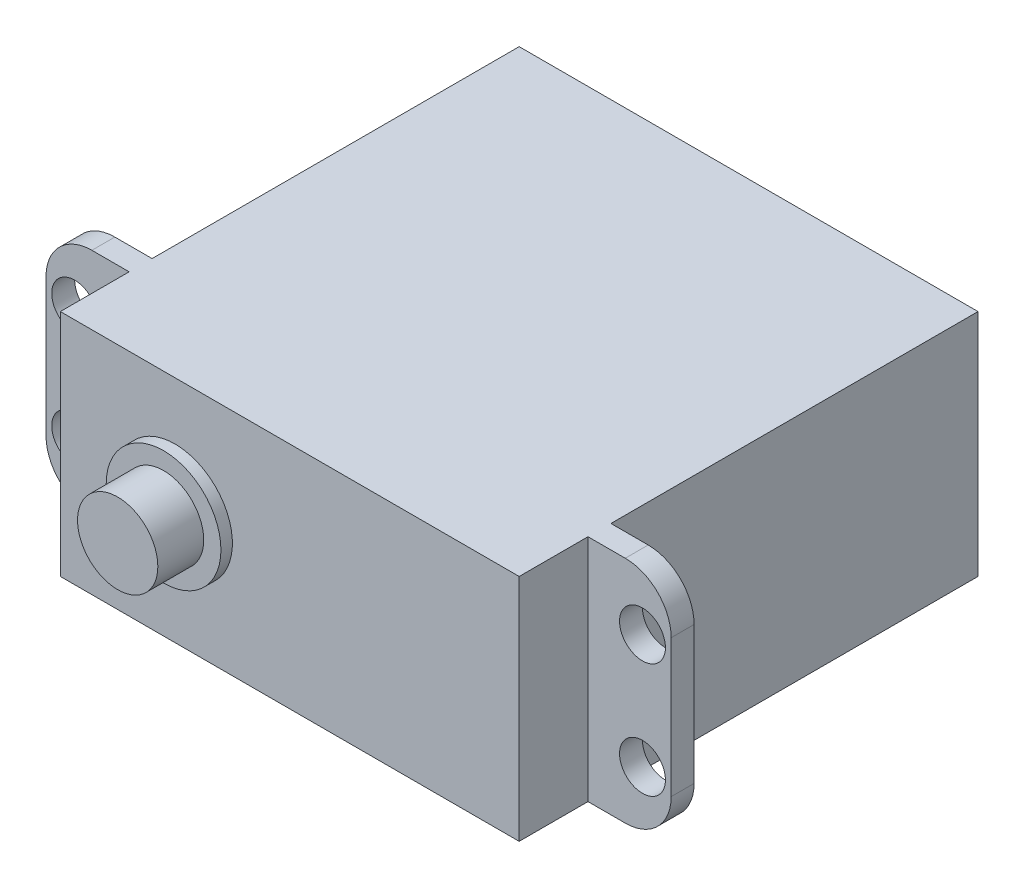
from build123d import *

# Parameters (mm, degrees)
SKETCH1_W           = 40
SKETCH1_H           = 20
BOSS_EXTRUDE2_DEPTH = 40
SKETCH2_W           = 2
SKETCH2_H           = 20
BOSS_EXTRUDE3_DEPTH = 7.25
SKETCH3_R           = 2
CUT_EXTRUDE1_DEPTH  = 2
FILLET3_R           = 4
SKETCH4_W           = 2
SKETCH4_H           = 20
BOSS_EXTRUDE4_DEPTH = 7.25
SKETCH5_R           = 2
CUT_EXTRUDE2_DEPTH  = 2
FILLET4_R           = 4
SKETCH6_R           = 5
BOSS_EXTRUDE5_DEPTH = 1
SKETCH7_R           = 3.5
BOSS_EXTRUDE7_DEPTH = 4
SKETCH9_R           = 5
BOSS_EXTRUDE8_DEPTH = 1
SKETCH10_R          = 3.5
BOSS_EXTRUDE9_DEPTH = 4


with BuildPart() as part:
    # Sketch1 → Boss-Extrude2 (new body)
    with BuildSketch(Plane.XY):
        Rectangle(SKETCH1_W, SKETCH1_H)
    extrude(amount=BOSS_EXTRUDE2_DEPTH)

    # Sketch2 → Boss-Extrude3 (add)
    with BuildSketch(Plane(origin=(20, 0, 0), x_dir=(0, 0, -1), z_dir=(1, 0, 0))):
        with Locations((-33, 0)):
            Rectangle(SKETCH2_W, SKETCH2_H)
    extrude(amount=BOSS_EXTRUDE3_DEPTH)

    # Sketch3 → Cut-Extrude1 (cut)
    with BuildSketch(Plane.XY.offset(34)):
        with Locations((24.75, -4.99913934)):
            Circle(SKETCH3_R)
        with Locations((24.75, 4.999429987)):
            Circle(SKETCH3_R)
    extrude(amount=-CUT_EXTRUDE1_DEPTH, mode=Mode.SUBTRACT)

    # Fillet3
    fillet3_edges = [part.edges().sort_by_distance(p)[0] for p in [
        (27.25, -10, 33),
        (27.25, 10, 33),
    ]]
    fillet(fillet3_edges, radius=FILLET3_R)

    # Sketch4 → Boss-Extrude4 (add)
    with BuildSketch(Plane.ZY.offset(20)):
        with Locations((33, 0)):
            Rectangle(SKETCH4_W, SKETCH4_H)
    extrude(amount=BOSS_EXTRUDE4_DEPTH)

    # Sketch5 → Cut-Extrude2 (cut)
    with BuildSketch(Plane.XY.offset(34)):
        with Locations((-24.75, 5)):
            Circle(SKETCH5_R)
        with Locations((-24.75, -5)):
            Circle(SKETCH5_R)
    extrude(amount=-CUT_EXTRUDE2_DEPTH, mode=Mode.SUBTRACT)

    # Fillet4
    fillet4_edges = [part.edges().sort_by_distance(p)[0] for p in [
        (-27.25, -10, 33),
        (-27.25, 10, 33),
    ]]
    fillet(fillet4_edges, radius=FILLET4_R)

    # Sketch6 → Boss-Extrude5 (add)
    with BuildSketch(Plane.XY.offset(40)):
        with Locations((-10, 0)):
            Circle(SKETCH6_R)
    extrude(amount=BOSS_EXTRUDE5_DEPTH)

    # Sketch7 → Boss-Extrude7 (add)
    with BuildSketch(Plane.XY.offset(41)):
        with Locations((-10, 0)):
            Circle(SKETCH7_R)
    extrude(amount=BOSS_EXTRUDE7_DEPTH)

    # Sketch9 → Boss-Extrude8 (add)
    with BuildSketch(Plane(origin=(0, 0, 0), x_dir=(-1, 0, 0), z_dir=(0, 0, -1))):
        with Locations((10, 0)):
            Circle(SKETCH9_R)
    extrude(amount=BOSS_EXTRUDE8_DEPTH)

    # Sketch10 → Boss-Extrude9 (add)
    with BuildSketch(Plane(origin=(0, 0, -1), x_dir=(-1, 0, 0), z_dir=(0, 0, -1))):
        with Locations((10, 0)):
            Circle(SKETCH10_R)
    extrude(amount=BOSS_EXTRUDE9_DEPTH)


solid = part.part
